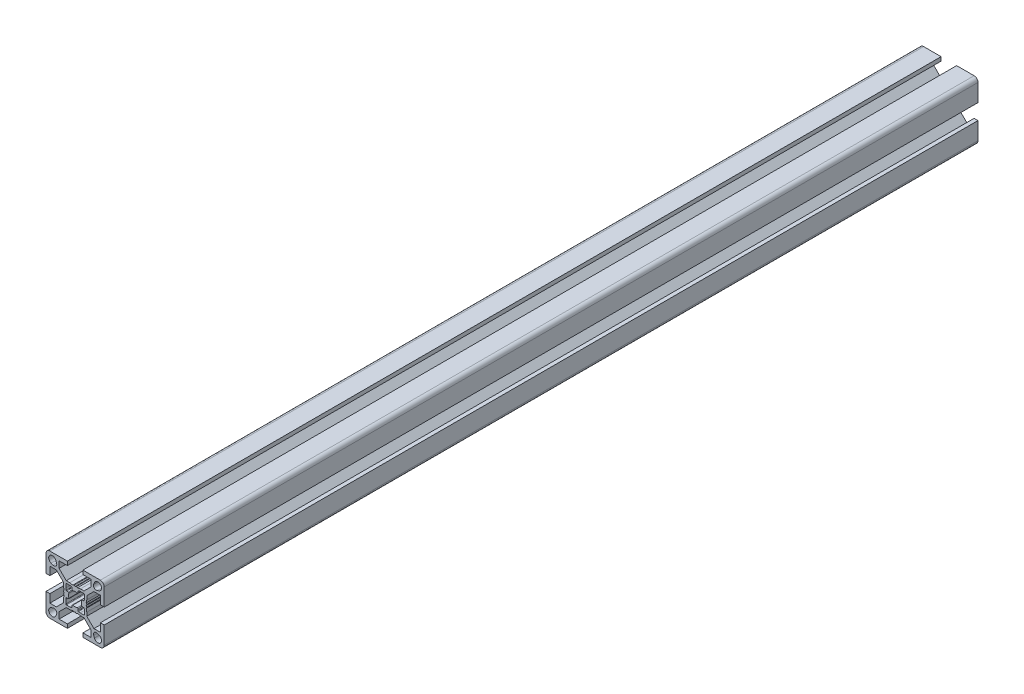
from build123d import *

# Parameters (mm, degrees)
ESTRUSIONE_ESTRUSIONE1_DEPTH = 450


with BuildPart() as part:
    # Schizzo1 → Estrusione-Estrusione1 (new body)
    with BuildSketch(Plane(origin=(0, 0, -450), x_dir=(-1, 0, 0), z_dir=(0, 0, -1))):
        with BuildLine():
            Line((9.664213562, 8.25), (13, 8.25))
            Line((13, 8.25), (13, 4))
            Line((13, 4), (15, 4))
            Line((15, 4), (15, 13))
            ThreePointArc((15, 13), (14.414213562, 14.414213562), (13, 15))
            Line((13, 15), (4, 15))
            Line((4, 15), (4, 13))
            Line((4, 13), (8.25, 13))
            Line((8.25, 13), (8.25, 9.664213562))
            add(Edge.make_bspline(
                [(8.25, 9.664213562), (7.028595479, 8.442809042), (5.807190958, 7.221404521), (4.585786438, 6)],
                knots=[0, 0, 0, 0, 1, 1, 1, 1], degree=3))
            Line((4.585786438, 6), (2.743366205, 6))
            Line((2.743366205, 6), (1.2, 5.7))
            Line((1.2, 5.7), (0.75, 5.959807621))
            ThreePointArc((0.75, 5.959807621), (0.6, 6), (0.45, 5.959807621))
            Line((0.45, 5.959807621), (0, 5.7))
            Line((0, 5.7), (-0.45, 5.959807621))
            ThreePointArc((-0.45, 5.959807621), (-0.6, 6), (-0.75, 5.959807621))
            Line((-0.75, 5.959807621), (-1.2, 5.7))
            Line((-1.2, 5.7), (-2.743366205, 6))
            Line((-2.743366205, 6), (-4.585786438, 6))
            add(Edge.make_bspline(
                [(-4.585786438, 6), (-5.807190958, 7.221404521), (-7.028595479, 8.442809042), (-8.25, 9.664213562)],
                knots=[0, 0, 0, 0, 1, 1, 1, 1], degree=3))
            Line((-8.25, 9.664213562), (-8.25, 13))
            Line((-8.25, 13), (-4, 13))
            Line((-4, 13), (-4, 15))
            Line((-4, 15), (-13, 15))
            ThreePointArc((-13, 15), (-14.414213562, 14.414213562), (-15, 13))
            Line((-15, 13), (-15, 4))
            Line((-15, 4), (-13, 4))
            Line((-13, 4), (-13, 8.25))
            Line((-13, 8.25), (-9.664213562, 8.25))
            add(Edge.make_bspline(
                [(-9.664213562, 8.25), (-8.442809042, 7.028595479), (-7.221404521, 5.807190958), (-6, 4.585786438)],
                knots=[0, 0, 0, 0, 1, 1, 1, 1], degree=3))
            Line((-6, 4.585786438), (-6, 2.743366205))
            Line((-6, 2.743366205), (-5.7, 1.2))
            Line((-5.7, 1.2), (-5.959807621, 0.75))
            ThreePointArc((-5.959807621, 0.75), (-6, 0.6), (-5.959807621, 0.45))
            Line((-5.959807621, 0.45), (-5.7, 0))
            Line((-5.7, 0), (-5.959807621, -0.45))
            ThreePointArc((-5.959807621, -0.45), (-6, -0.6), (-5.959807621, -0.75))
            Line((-5.959807621, -0.75), (-5.7, -1.2))
            Line((-5.7, -1.2), (-6, -2.743366205))
            Line((-6, -2.743366205), (-6, -4.585786438))
            add(Edge.make_bspline(
                [(-6, -4.585786438), (-7.221404521, -5.807190958), (-8.442809042, -7.028595479), (-9.664213562, -8.25)],
                knots=[0, 0, 0, 0, 1, 1, 1, 1], degree=3))
            Line((-9.664213562, -8.25), (-13, -8.25))
            Line((-13, -8.25), (-13, -4))
            Line((-13, -4), (-15, -4))
            Line((-15, -4), (-15, -13))
            ThreePointArc((-15, -13), (-14.414213562, -14.414213562), (-13, -15))
            Line((-13, -15), (-4, -15))
            Line((-4, -15), (-4, -13))
            Line((-4, -13), (-8.25, -13))
            Line((-8.25, -13), (-8.25, -9.664213562))
            add(Edge.make_bspline(
                [(-8.25, -9.664213562), (-7.028595479, -8.442809042), (-5.807190958, -7.221404521), (-4.585786438, -6)],
                knots=[0, 0, 0, 0, 1, 1, 1, 1], degree=3))
            Line((-4.585786438, -6), (-2.743366205, -6))
            Line((-2.743366205, -6), (-1.2, -5.7))
            Line((-1.2, -5.7), (-0.75, -5.959807621))
            ThreePointArc((-0.75, -5.959807621), (-0.6, -6), (-0.45, -5.959807621))
            Line((-0.45, -5.959807621), (0, -5.7))
            Line((0, -5.7), (0.45, -5.959807621))
            ThreePointArc((0.45, -5.959807621), (0.6, -6), (0.75, -5.959807621))
            Line((0.75, -5.959807621), (1.2, -5.7))
            Line((1.2, -5.7), (2.743366205, -6))
            Line((2.743366205, -6), (4.585786438, -6))
            add(Edge.make_bspline(
                [(4.585786438, -6), (5.807190958, -7.221404521), (7.028595479, -8.442809042), (8.25, -9.664213562)],
                knots=[0, 0, 0, 0, 1, 1, 1, 1], degree=3))
            Line((8.25, -9.664213562), (8.25, -13))
            Line((8.25, -13), (4, -13))
            Line((4, -13), (4, -15))
            Line((4, -15), (13, -15))
            ThreePointArc((13, -15), (14.414213562, -14.414213562), (15, -13))
            Line((15, -13), (15, -4))
            Line((15, -4), (13, -4))
            Line((13, -4), (13, -8.25))
            Line((13, -8.25), (9.664213562, -8.25))
            add(Edge.make_bspline(
                [(9.664213562, -8.25), (8.442809042, -7.028595479), (7.221404521, -5.807190958), (6, -4.585786438)],
                knots=[0, 0, 0, 0, 1, 1, 1, 1], degree=3))
            Line((6, -4.585786438), (6, -2.743366205))
            Line((6, -2.743366205), (5.7, -1.2))
            Line((5.7, -1.2), (5.959807621, -0.75))
            ThreePointArc((5.959807621, -0.75), (6, -0.6), (5.959807621, -0.45))
            Line((5.959807621, -0.45), (5.7, 0))
            Line((5.7, 0), (5.959807621, 0.45))
            ThreePointArc((5.959807621, 0.45), (6, 0.6), (5.959807621, 0.75))
            Line((5.959807621, 0.75), (5.700000037, 1.199999936))
            Line((5.700000037, 1.199999936), (6, 2.743366205))
            Line((6, 2.743366205), (6, 4.585786438))
            add(Edge.make_bspline(
                [(6, 4.585786438), (7.221404521, 5.807190958), (8.442809042, 7.028595479), (9.664213562, 8.25)],
                knots=[0, 0, 0, 0, 1, 1, 1, 1], degree=3))
        make_face()
        with BuildLine():
            Line((9.918883282, -12.361530981), (9.539070071, -11.338915743))
            ThreePointArc((9.539070071, -11.338915743), (9.861522369, -9.861522369), (11.338915743, -9.539070071))
            Line((11.338915743, -9.539070071), (12.361530981, -9.918883282))
            ThreePointArc((12.361530981, -9.918883282), (13.043502884, -13.043502884), (9.918883282, -12.361530981))
        make_face(mode=Mode.SUBTRACT)
        with BuildLine():
            Line((12.361530981, 9.918883282), (11.338915743, 9.539070071))
            ThreePointArc((11.338915743, 9.539070071), (9.861522369, 9.861522369), (9.539070071, 11.338915743))
            Line((9.539070071, 11.338915743), (9.918883282, 12.361530981))
            ThreePointArc((9.918883282, 12.361530981), (13.043502884, 13.043502884), (12.361530981, 9.918883282))
        make_face(mode=Mode.SUBTRACT)
        with BuildLine():
            Line((-9.539070071, -11.338915743), (-9.918883282, -12.361530981))
            ThreePointArc((-9.918883282, -12.361530981), (-13.043502884, -13.043502884), (-12.361530981, -9.918883282))
            Line((-12.361530981, -9.918883282), (-11.338915743, -9.539070071))
            ThreePointArc((-11.338915743, -9.539070071), (-9.861522369, -9.861522369), (-9.539070071, -11.338915743))
        make_face(mode=Mode.SUBTRACT)
        with BuildLine():
            Line((-11.338915743, 9.539070071), (-12.361530981, 9.918883282))
            ThreePointArc((-12.361530981, 9.918883282), (-13.043502884, 13.043502884), (-9.918883282, 12.361530981))
            Line((-9.918883282, 12.361530981), (-9.539070071, 11.338915743))
            ThreePointArc((-9.539070071, 11.338915743), (-9.861522369, 9.861522369), (-11.338915743, 9.539070071))
        make_face(mode=Mode.SUBTRACT)
        with BuildLine():
            Line((4.8, -2.644433572), (4.8, -4.5))
            ThreePointArc((4.8, -4.5), (4.712132034, -4.712132034), (4.5, -4.8))
            Line((4.5, -4.8), (2.644433572, -4.8))
            ThreePointArc((2.644433572, -4.8), (2.615679847, -4.79861886), (2.587190874, -4.794488155))
            Line((2.587190874, -4.794488155), (1.742757301, -4.630346896))
            ThreePointArc((1.742757301, -4.630346896), (1.568512625, -4.526682207), (1.5, -4.335858741))
            Line((1.5, -4.335858741), (1.5, -3.5))
            ThreePointArc((1.5, -3.5), (1.374371458, -3.255879959), (1.102702703, -3.216216216))
            ThreePointArc((1.102702703, -3.216216216), (0, -3.4), (-1.102702703, -3.216216216))
            ThreePointArc((-1.102702703, -3.216216216), (-1.374371458, -3.255879959), (-1.5, -3.5))
            Line((-1.5, -3.5), (-1.5, -4.335858741))
            ThreePointArc((-1.5, -4.335858741), (-1.568512625, -4.526682207), (-1.742757301, -4.630346896))
            Line((-1.742757301, -4.630346896), (-2.587190874, -4.794488155))
            ThreePointArc((-2.587190874, -4.794488155), (-2.615679847, -4.79861886), (-2.644433572, -4.8))
            Line((-2.644433572, -4.8), (-4.5, -4.8))
            ThreePointArc((-4.5, -4.8), (-4.712132034, -4.712132034), (-4.8, -4.5))
            Line((-4.8, -4.5), (-4.8, -2.644433572))
            ThreePointArc((-4.8, -2.644433572), (-4.79861886, -2.615679847), (-4.794488155, -2.587190874))
            Line((-4.794488155, -2.587190874), (-4.630346896, -1.742757301))
            ThreePointArc((-4.630346896, -1.742757301), (-4.526682207, -1.568512625), (-4.335858741, -1.5))
            Line((-4.335858741, -1.5), (-3.5, -1.5))
            ThreePointArc((-3.5, -1.5), (-3.255879959, -1.374371458), (-3.216216216, -1.102702703))
            ThreePointArc((-3.216216216, -1.102702703), (-3.4, 0), (-3.216216216, 1.102702703))
            ThreePointArc((-3.216216216, 1.102702703), (-3.255879959, 1.374371458), (-3.5, 1.5))
            Line((-3.5, 1.5), (-4.335858741, 1.5))
            ThreePointArc((-4.335858741, 1.5), (-4.526682207, 1.568512625), (-4.630346896, 1.742757301))
            Line((-4.630346896, 1.742757301), (-4.794488155, 2.587190874))
            ThreePointArc((-4.794488155, 2.587190874), (-4.79861886, 2.615679847), (-4.8, 2.644433572))
            Line((-4.8, 2.644433572), (-4.8, 4.5))
            ThreePointArc((-4.8, 4.5), (-4.712132034, 4.712132034), (-4.5, 4.8))
            Line((-4.5, 4.8), (-2.644433572, 4.8))
            ThreePointArc((-2.644433572, 4.8), (-2.615679847, 4.79861886), (-2.587190874, 4.794488155))
            Line((-2.587190874, 4.794488155), (-1.742757301, 4.630346896))
            ThreePointArc((-1.742757301, 4.630346896), (-1.568512625, 4.526682207), (-1.5, 4.335858741))
            Line((-1.5, 4.335858741), (-1.5, 3.5))
            ThreePointArc((-1.5, 3.5), (-1.374371458, 3.255879959), (-1.102702703, 3.216216216))
            ThreePointArc((-1.102702703, 3.216216216), (0, 3.4), (1.102702703, 3.216216216))
            ThreePointArc((1.102702703, 3.216216216), (1.374371458, 3.255879959), (1.5, 3.5))
            Line((1.5, 3.5), (1.5, 4.335858741))
            ThreePointArc((1.5, 4.335858741), (1.568512625, 4.526682207), (1.742757301, 4.630346896))
            Line((1.742757301, 4.630346896), (2.587190874, 4.794488155))
            ThreePointArc((2.587190874, 4.794488155), (2.615679847, 4.79861886), (2.644433572, 4.8))
            Line((2.644433572, 4.8), (4.5, 4.8))
            ThreePointArc((4.5, 4.8), (4.712132034, 4.712132034), (4.8, 4.5))
            Line((4.8, 4.5), (4.8, 2.644433572))
            ThreePointArc((4.8, 2.644433572), (4.79861886, 2.615679847), (4.794488155, 2.587190874))
            Line((4.794488155, 2.587190874), (4.630346896, 1.742757301))
            ThreePointArc((4.630346896, 1.742757301), (4.526682207, 1.568512625), (4.335858741, 1.5))
            Line((4.335858741, 1.5), (3.5, 1.5))
            ThreePointArc((3.5, 1.5), (3.255879959, 1.374371458), (3.216216216, 1.102702703))
            ThreePointArc((3.216216216, 1.102702703), (3.4, 0), (3.216216216, -1.102702703))
            ThreePointArc((3.216216216, -1.102702703), (3.255879959, -1.374371458), (3.5, -1.5))
            Line((3.5, -1.5), (4.335858741, -1.5))
            ThreePointArc((4.335858741, -1.5), (4.526682207, -1.568512625), (4.630346896, -1.742757301))
            Line((4.630346896, -1.742757301), (4.794488155, -2.587190874))
            ThreePointArc((4.794488155, -2.587190874), (4.79861886, -2.615679847), (4.8, -2.644433572))
        make_face(mode=Mode.SUBTRACT)
    extrude(amount=-ESTRUSIONE_ESTRUSIONE1_DEPTH)


solid = part.part
